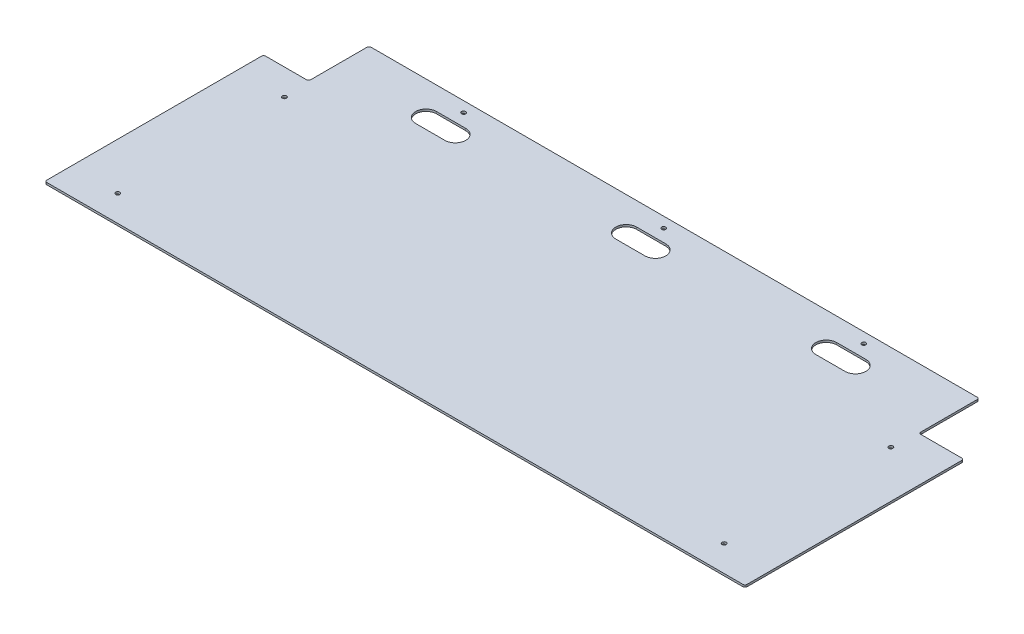
from build123d import *

# Parameters (mm, degrees)
SKETCH1_W                   = 1066.8
SKETCH1_H                   = 333.375
BOSS_EXTRUDE1_DEPTH         = 3.175
SKETCH2_W                   = 929.64
SKETCH2_H                   = 92.075
BOSS_EXTRUDE2_DEPTH         = 3.175
F_1_4_0_25_DIAMETER_HOLE1_D = 6.35
FILLET1_R                   = 3.175
CUT_EXTRUDE1_DEPTH          = 4.175


with BuildPart() as part:
    # Sketch1 → Boss-Extrude1 (new body)
    with BuildSketch(Plane(origin=(0, 0, 0), x_dir=(1, 0, 0), z_dir=(0, 1, 0))):
        with Locations((533.4, 166.6875)):
            Rectangle(SKETCH1_W, SKETCH1_H)
    extrude(amount=BOSS_EXTRUDE1_DEPTH)

    # Sketch2 → Boss-Extrude2 (add)
    with BuildSketch(Plane(origin=(0, 3.175, 0), x_dir=(1, 0, 0), z_dir=(0, 1, 0))):
        with Locations((533.4, 379.4125)):
            Rectangle(SKETCH2_W, SKETCH2_H)
    extrude(amount=-BOSS_EXTRUDE2_DEPTH)

    # 1/4 (0.25) Diameter Hole1 (through all)
    with Locations(Plane(origin=(0, 0, 0), x_dir=(-1, 0, 0), z_dir=(0, -1, 0))):
        with Locations((-71.4375, 39.6875), (-228.6, 409.575), (-533.4, 409.575), (-838.2, 409.575), (-995.3625, 293.6875), (-995.3625, 39.6875), (-71.4375, 293.6875)):
            Hole(F_1_4_0_25_DIAMETER_HOLE1_D / 2)

    # Fillet1
    fillet1_edges = [part.edges().sort_by_distance(p)[0] for p in [
        (998.22, 1.5875, -333.375),
        (998.22, 1.5875, -425.45),
        (68.58, 1.5875, -425.45),
        (68.58, 1.5875, -333.375),
        (0, 1.5875, -333.375),
        (1066.8, 1.5875, -333.375),
        (1066.8, 1.5875, 0),
        (0, 1.5875, 0),
    ]]
    fillet(fillet1_edges, radius=FILLET1_R)

    # Sketch9 → Cut-Extrude1 (cut, through all)
    with BuildSketch(Plane.XZ):
        with BuildLine():
            Line((860.425, -390.525), (815.975, -390.525))
            ThreePointArc((815.975, -390.525), (800.1, -374.65), (815.975, -358.775))
            Line((815.975, -358.775), (860.425, -358.775))
            ThreePointArc((860.425, -358.775), (876.3, -374.65), (860.425, -390.525))
        make_face()
        with BuildLine():
            Line((555.625, -390.525), (511.175, -390.525))
            ThreePointArc((511.175, -390.525), (495.3, -374.65), (511.175, -358.775))
            Line((511.175, -358.775), (555.625, -358.775))
            ThreePointArc((555.625, -358.775), (571.5, -374.65), (555.625, -390.525))
        make_face()
        with BuildLine():
            Line((250.825, -390.525), (206.375, -390.525))
            ThreePointArc((206.375, -390.525), (190.5, -374.65), (206.375, -358.775))
            Line((206.375, -358.775), (250.825, -358.775))
            ThreePointArc((250.825, -358.775), (266.7, -374.65), (250.825, -390.525))
        make_face()
    extrude(amount=-CUT_EXTRUDE1_DEPTH, mode=Mode.SUBTRACT)


solid = part.part
